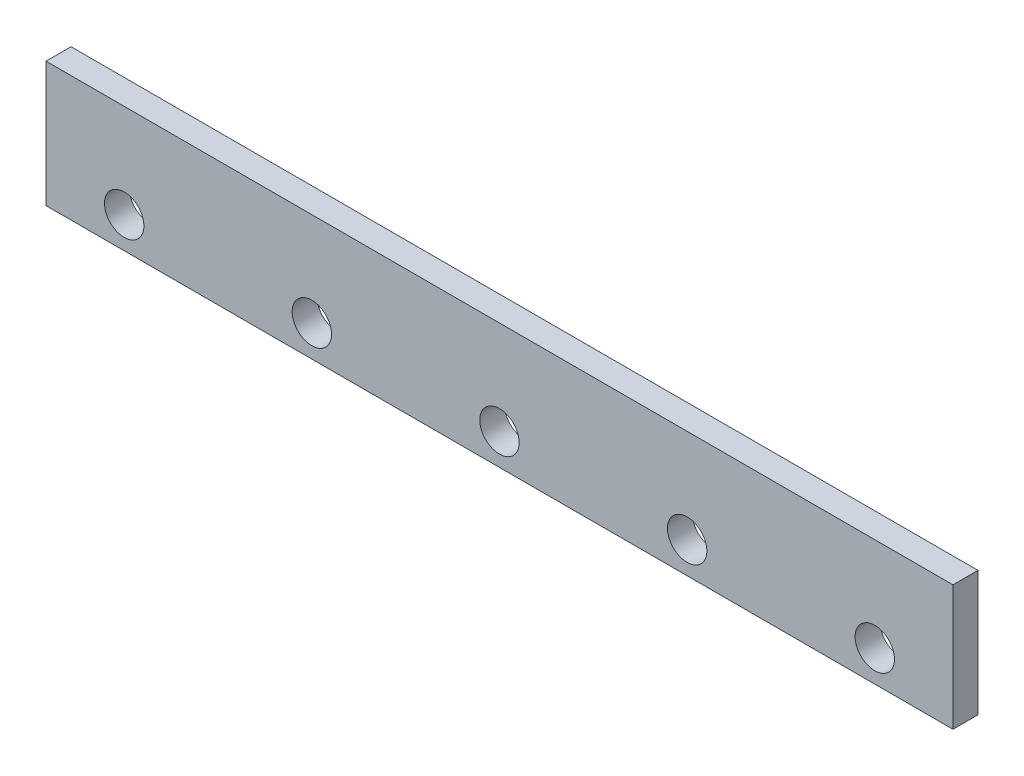
from build123d import *

# Parameters (mm, degrees)
SKETCH1_W           = 580
SKETCH1_H           = 80
BOSS_EXTRUDE1_DEPTH = 16
SKETCH5_R           = 12.6
CUT_EXTRUDE1_DEPTH  = 16


with BuildPart() as part:
    # Sketch1 → Boss-Extrude1 (new body)
    with BuildSketch(Plane.XY):
        with Locations((290, 40)):
            Rectangle(SKETCH1_W, SKETCH1_H)
    extrude(amount=BOSS_EXTRUDE1_DEPTH)

    # Sketch5 → Cut-Extrude1 (cut)
    with BuildSketch(Plane.XY.offset(16)):
        with Locations((50, 20)):
            Circle(SKETCH5_R)
        with Locations((170, 20)):
            Circle(SKETCH5_R)
        with Locations((290, 20)):
            Circle(SKETCH5_R)
        with Locations((410, 20)):
            Circle(SKETCH5_R)
        with Locations((530, 20)):
            Circle(SKETCH5_R)
    extrude(amount=-CUT_EXTRUDE1_DEPTH, mode=Mode.SUBTRACT)


solid = part.part
